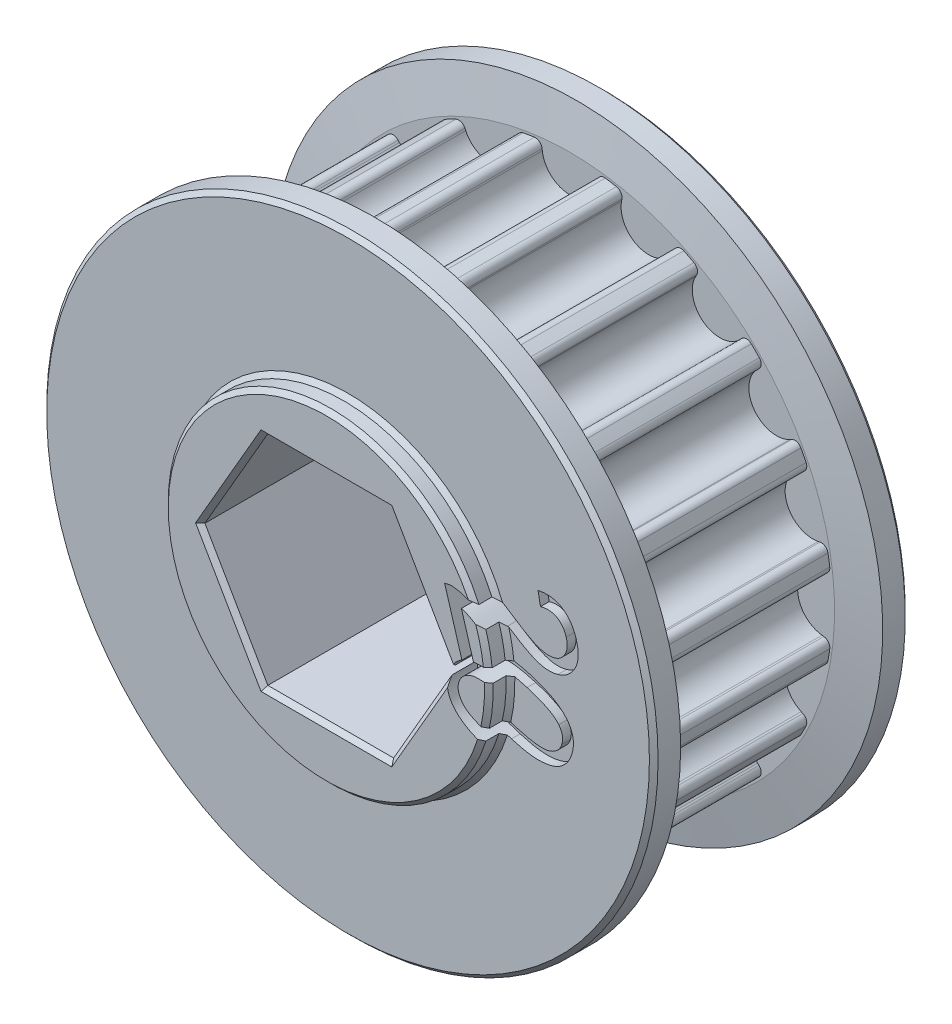
from build123d import *

# Parameters (mm, degrees)
SKETCH2_R                                 = 15.381132683
PULLEY_DEPTH                              = 5.500000049
CUT_TOOTH_DEPTH                           = 5.500000049
BLEND_TOOTH_R                             = 0.4
TOOTH_PATTERN_COUNT                       = 20
BLEND_TOOTH_OF_TOOTH_PATTERN_R            = 0.4
SIDEWALL_START                            = 5.500000049
SKETCH3_R                                 = 17.921132683
SIDEWALL_DEPTH                            = 2.000000064
SIDEWALL_CHAMFER_SIZE                     = 2.400000026
SIDEWALL_CHAMFER_SIZE2                    = 0.423184758
SIDEWALL_CHAMFER_PART_2_SIZE              = 2.400000026
SIDEWALL_CHAMFER_PART_2_SIZE2             = 0.423184758
SKETCH5_R                                 = 9.525
BEARING_SPACER_MANUAL_SUPPRESS_DEPTH      = 8.770000113
BEARING_SPACER_MANUAL_SUPPRESS_DEPTH_BACK = 8.770000113
HEX_SHAFT_DEPTH                           = 63.5
CHAMFERS_SIZE                             = 0.254
CUT_EXTRUDE_START                         = 6.992000113
CUT_EXTRUDE_4419_DEPTH                    = 2.54


with BuildPart() as part:
    # Sketch2 → pulley (new body, symmetric)
    with BuildSketch(Plane.XY):
        Circle(SKETCH2_R)
    extrude(amount=PULLEY_DEPTH, both=True)

    # tooth → cut tooth (cut, symmetric)
    with BuildSketch(Plane.XY):
        with BuildLine():
            Line((-2.132711961, 19.01672513), (-1.612887548, 14.783095032))
            ThreePointArc((-1.612887548, 14.783095032), (0, 13.356132669), (1.612887548, 14.783095032))
            Line((1.612887548, 14.783095032), (2.132711961, 19.01672513))
            Line((2.132711961, 19.01672513), (-2.132711961, 19.01672513))
        make_face()
    cut_tooth = extrude(amount=CUT_TOOTH_DEPTH, both=True, mode=Mode.SUBTRACT)

    # blend tooth
    blend_tooth_edges = [part.edges().sort_by_distance(p)[0] for p in [
        (1.675084427, 15.289647961, 0),
        (-1.675084427, 15.289647961, 0),
    ]]
    fillet(blend_tooth_edges, radius=BLEND_TOOTH_R)

    # tooth pattern: cut tooth ×20 about axis
    tooth_pattern_axis = Axis((0, 0, 0), (0, 0, 1))
    for i in range(1, TOOTH_PATTERN_COUNT):
        add(cut_tooth.rotate(tooth_pattern_axis, i * 360 / TOOTH_PATTERN_COUNT), mode=Mode.SUBTRACT)

    # blend tooth of tooth pattern
    blend_tooth_of_tooth_pattern_edges = [part.edges().sort_by_distance(p)[0] for p in [
        (-3.131661098, 15.058948881, 0),
        (-6.317861018, 14.023689771, 0),
        (-7.631857816, 13.354174961, 0),
        (-10.342201353, 11.384995116, 0),
        (-11.384995116, 10.342201353, 0),
        (-13.354174961, 7.631857816, 0),
        (-14.023689771, 6.317861018, 0),
        (-15.058948881, 3.131661098, 0),
        (-15.289647961, 1.675084427, 0),
        (-15.289647961, -1.675084427, 0),
        (-15.058948881, -3.131661098, 0),
        (-14.023689771, -6.317861018, 0),
        (-13.354174961, -7.631857816, 0),
        (-11.384995116, -10.342201353, 0),
        (-10.342201353, -11.384995116, 0),
        (-7.631857816, -13.354174961, 0),
        (-6.317861018, -14.023689771, 0),
        (-3.131661098, -15.058948881, 0),
        (-1.675084427, -15.289647961, 0),
        (1.675084427, -15.289647961, 0),
        (3.131661098, -15.058948881, 0),
        (6.317861018, -14.023689771, 0),
        (7.631857816, -13.354174961, 0),
        (10.342201353, -11.384995116, 0),
        (11.384995116, -10.342201353, 0),
        (13.354174961, -7.631857816, 0),
        (14.023689771, -6.317861018, 0),
        (15.058948881, -3.131661098, 0),
        (15.289647961, -1.675084427, 0),
        (15.289647961, 1.675084427, 0),
        (15.058948881, 3.131661098, 0),
        (14.023689771, 6.317861018, 0),
        (13.354174961, 7.631857816, 0),
        (11.384995116, 10.342201353, 0),
        (10.342201353, 11.384995116, 0),
        (7.631857816, 13.354174961, 0),
        (6.317861018, 14.023689771, 0),
        (3.131661098, 15.058948881, 0),
    ]]
    fillet(blend_tooth_of_tooth_pattern_edges, radius=BLEND_TOOTH_OF_TOOTH_PATTERN_R)

    # Sketch3 → sidewall (add)
    with BuildSketch(Plane.XY.offset(SIDEWALL_START)):
        Circle(SKETCH3_R)
    sidewall = extrude(amount=SIDEWALL_DEPTH)

    # mirror sidewall: sidewall across plane
    add(sidewall.mirror(Plane.XY))

    # sidewall chamfer
    sidewall_chamfer_edges = [part.edges().sort_by_distance(p)[0] for p in [
        (-17.921132683, 0, 5.500000049),
    ]]
    sidewall_chamfer_side = [part.faces().sort_by_distance(p)[0] for p in [
        (-17.414246505, 0, 5.500000049),
    ]]
    chamfer(sidewall_chamfer_edges, length=SIDEWALL_CHAMFER_SIZE, length2=SIDEWALL_CHAMFER_SIZE2, reference=sidewall_chamfer_side[0])

    # sidewall chamfer part 2
    sidewall_chamfer_part_2_edges = [part.edges().sort_by_distance(p)[0] for p in [
        (-17.921132683, 0, -5.500000049),
    ]]
    sidewall_chamfer_part_2_side = [part.faces().sort_by_distance(p)[0] for p in [
        (-17.414246505, 0, -5.500000049),
    ]]
    chamfer(sidewall_chamfer_part_2_edges, length=SIDEWALL_CHAMFER_PART_2_SIZE, length2=SIDEWALL_CHAMFER_PART_2_SIZE2, reference=sidewall_chamfer_part_2_side[0])

    # Sketch5 → bearing spacer (Manual Suppress) (add, two sides)
    with BuildSketch(Plane.XY) as bearing_spacer_manual_suppress_sk:
        Circle(SKETCH5_R)
    extrude(amount=BEARING_SPACER_MANUAL_SUPPRESS_DEPTH)
    extrude(bearing_spacer_manual_suppress_sk.sketch, amount=-BEARING_SPACER_MANUAL_SUPPRESS_DEPTH_BACK)

    # Sketch4 → hex shaft (cut, symmetric)
    with BuildSketch(Plane.XY):
        Polygon((3.688171255, 6.3881), (-3.688171255, 6.3881), (-7.376342509, 0), (-3.688171255, -6.3881), (3.688171255, -6.3881), (7.376342509, 0), align=None)
    extrude(amount=HEX_SHAFT_DEPTH, both=True, mode=Mode.SUBTRACT)

    # chamfers
    chamfers_edges = [part.edges().sort_by_distance(p)[0] for p in [
        (-17.921132683, 0, 7.500000113),
        (-17.921132683, 0, -7.500000113),
        (-9.525, 0, -7.500000113),
        (-9.525, 0, 7.500000113),
        (-9.525, 0, -8.770000113),
        (-9.525, 0, 8.770000113),
        (0, 6.3881, 8.770000113),
        (-5.532256882, 3.19405, 8.770000113),
        (-5.532256882, -3.19405, 8.770000113),
        (0, -6.3881, 8.770000113),
        (5.532256882, -3.19405, 8.770000113),
        (5.532256882, 3.19405, 8.770000113),
        (5.532256882, 3.19405, -8.770000113),
        (5.532256882, -3.19405, -8.770000113),
        (0, -6.3881, -8.770000113),
        (-5.532256882, -3.19405, -8.770000113),
        (-5.532256882, 3.19405, -8.770000113),
        (0, 6.3881, -8.770000113),
    ]]
    chamfer(chamfers_edges, length=CHAMFERS_SIZE)

    # Sketch6 → 4419 (cut)
    with BuildSketch(Plane.XY.offset(CUT_EXTRUDE_START)):
        with BuildLine():
            Line((8.766198019, 0.589858789), (8.07843191, 0.384887202))
            Line((8.07843191, 0.384887202), (6.931331882, 4.236130461))
            add(Edge.make_bspline(
                [(6.931331882, 4.236130461), (6.973928693, 4.24890387), (7.058624263, 4.274301337), (7.188956622, 4.297427056), (7.320577394, 4.308171263), (7.408360376, 4.303777636), (7.45240423, 4.301573196)],
                knots=[0, 0, 0, 0, 0.000133315, 0.000265071, 0.000396329, 0.000528501, 0.000528501, 0.000528501, 0.000528501], degree=3))
            add(Edge.make_bspline(
                [(7.45240423, 4.301573196), (7.526313154, 4.294486229), (7.677039723, 4.280033383), (7.903958115, 4.228030061), (8.136041701, 4.156614255), (8.331820725, 4.078466956), (8.492790819, 4.003004587), (8.622180148, 3.939004595), (8.75826156, 3.867338495), (8.900297464, 3.787001851), (9.047747953, 3.697658951), (9.203000258, 3.602533506), (9.364552461, 3.499056292), (9.473462339, 3.42553063), (9.529285013, 3.387844434)],
                knots=[0, 0, 0, 0, 0.000222539, 0.000453837, 0.00069677, 0.000950595, 0.001085389, 0.001230067, 0.001383616, 0.001546727, 0.001719524, 0.001900804, 0.002092956, 0.00229501, 0.00229501, 0.00229501, 0.00229501], degree=3))
            add(Edge.make_bspline(
                [(9.529285013, 3.387844434), (9.614599201, 3.330180573), (9.779190501, 3.218933311), (10.021913289, 3.065421957), (10.246942179, 2.92510911), (10.457204794, 2.802876813), (10.650966346, 2.696343509), (10.828965964, 2.60545543), (10.991676244, 2.531230748), (11.140639732, 2.471548378), (11.279552066, 2.426926064), (11.411296301, 2.391574377), (11.538778274, 2.366647366), (11.66174668, 2.35191917), (11.779907198, 2.345980544), (11.892998473, 2.353150256), (12.001997275, 2.366625033), (12.071824867, 2.384864422), (12.106247078, 2.393855712)],
                knots=[0, 0, 0, 0, 0.000308902, 0.000595945, 0.000861515, 0.001104426, 0.001325463, 0.001524812, 0.00170385, 0.001861832, 0.00200592, 0.002141295, 0.002270851, 0.002395214, 0.002512621, 0.002625154, 0.00273482, 0.00284144, 0.00284144, 0.00284144, 0.00284144], degree=3))
            add(Edge.make_bspline(
                [(12.106247078, 2.393855712), (12.140684562, 2.405081651), (12.208770866, 2.427276441), (12.304725448, 2.472435455), (12.395111251, 2.523818193), (12.475818005, 2.586386619), (12.551665896, 2.654794725), (12.619040235, 2.732719127), (12.679957702, 2.818868355), (12.733993812, 2.911537215), (12.778236064, 3.010586839), (12.813330509, 3.113355771), (12.836638251, 3.219819436), (12.849021003, 3.329044779), (12.850221664, 3.441173362), (12.839657799, 3.555922962), (12.820404698, 3.674251321), (12.79886897, 3.752680602), (12.787839344, 3.792848534)],
                knots=[0, 0, 0, 0, 0.000108561, 0.000214637, 0.00031756, 0.0004198, 0.000520303, 0.000623567, 0.000728064, 0.000836499, 0.000944821, 0.001052981, 0.001161732, 0.001271091, 0.001382227, 0.001497485, 0.00161644, 0.001741323, 0.001741323, 0.001741323, 0.001741323], degree=3))
            add(Edge.make_bspline(
                [(12.787839344, 3.792848534), (12.774641239, 3.834707149), (12.748855912, 3.91648693), (12.69767548, 4.031579691), (12.63886556, 4.137355115), (12.574592323, 4.235529839), (12.499113341, 4.322173155), (12.417846455, 4.400663876), (12.327901181, 4.468667308), (12.232005618, 4.528332076), (12.129060371, 4.57624541), (12.02124193, 4.613954076), (11.908366485, 4.637999366), (11.790969182, 4.652234147), (11.668938301, 4.652592231), (11.542456361, 4.643003051), (11.411643971, 4.620117688), (11.324076942, 4.597318695), (11.278952117, 4.585569974)],
                knots=[0, 0, 0, 0, 0.000131588, 0.000257086, 0.000377018, 0.000494483, 0.000608323, 0.000720985, 0.000832859, 0.000945947, 0.001059183, 0.001172815, 0.001287861, 0.001404721, 0.001526969, 0.001653303, 0.001784844, 0.001924701, 0.001924701, 0.001924701, 0.001924701], degree=3))
            Line((11.278952117, 4.585569974), (11.135718959, 5.342483125))
            add(Edge.make_bspline(
                [(11.135718959, 5.342483125), (11.204697722, 5.355186393), (11.339127766, 5.379943302), (11.538736352, 5.396524061), (11.729960118, 5.39867513), (11.912855296, 5.383007101), (12.087326445, 5.349247288), (12.253591184, 5.299632235), (12.412369273, 5.234748757), (12.561350204, 5.150876668), (12.700661422, 5.052211173), (12.830182114, 4.938850446), (12.949164328, 4.81088582), (13.057992973, 4.668044387), (13.157177671, 4.510811286), (13.244344348, 4.337988601), (13.322811474, 4.151716772), (13.364286535, 4.020420081), (13.385467346, 3.953368452)],
                knots=[0, 0, 0, 0, 0.000210303, 0.00040985, 0.000600009, 0.000783458, 0.000959511, 0.001132185, 0.001303248, 0.001472951, 0.001643908, 0.001814543, 0.0019884, 0.002167203, 0.002352537, 0.002545264, 0.002747291, 0.002958144, 0.002958144, 0.002958144, 0.002958144], degree=3))
            add(Edge.make_bspline(
                [(13.385467346, 3.953368452), (13.404265986, 3.884891979), (13.441005143, 3.751064855), (13.476358108, 3.550659046), (13.495889354, 3.35704857), (13.496271151, 3.169608742), (13.477180998, 2.989025672), (13.443208993, 2.814532451), (13.389775385, 2.646712437), (13.317720069, 2.487377523), (13.233381012, 2.336762539), (13.135292329, 2.199251962), (13.026285302, 2.074872672), (12.905455129, 1.964383391), (12.773662348, 1.866077306), (12.63035296, 1.780698287), (12.474428963, 1.709645407), (12.364701808, 1.673761971), (12.308749128, 1.65546409)],
                knots=[0, 0, 0, 0, 0.000212932, 0.000416145, 0.000609657, 0.000796107, 0.000977332, 0.001153623, 0.001328569, 0.00150434, 0.001677406, 0.001845634, 0.002010113, 0.002172662, 0.002335899, 0.002502557, 0.002672192, 0.0028487, 0.0028487, 0.0028487, 0.0028487], degree=3))
            add(Edge.make_bspline(
                [(12.308749128, 1.65546409), (12.250170793, 1.639717555), (12.132957395, 1.608209236), (11.950953691, 1.584958513), (11.765745382, 1.576532367), (11.575068717, 1.59005538), (11.376703949, 1.621993285), (11.169095403, 1.679449415), (10.94957845, 1.756456674), (10.759281475, 1.838587313), (10.595601297, 1.917476032), (10.459121288, 1.991496161), (10.308495548, 2.073216535), (10.145936708, 2.168311674), (9.970664749, 2.273807955), (9.781908866, 2.390343287), (9.581553115, 2.518747191), (9.443630046, 2.608225861), (9.372469401, 2.654391886)],
                knots=[0, 0, 0, 0, 0.000181784, 0.000363744, 0.000549107, 0.000737198, 0.000936133, 0.001150887, 0.001382461, 0.001633606, 0.001772219, 0.001927437, 0.002099301, 0.002286306, 0.002492349, 0.002713024, 0.002951769, 0.003206243, 0.003206243, 0.003206243, 0.003206243], degree=3))
            add(Edge.make_bspline(
                [(9.372469401, 2.654391886), (9.314068403, 2.692737903), (9.202415741, 2.766048891), (9.041956723, 2.869875539), (8.896397841, 2.962064836), (8.766456958, 3.044427115), (8.651375157, 3.114023657), (8.551373165, 3.172922471), (8.467040862, 3.220794372), (8.336908311, 3.290716169), (8.156892649, 3.373554883), (7.993003421, 3.424063994), (7.914207686, 3.448348095)],
                knots=[0, 0, 0, 0, 0.000209594, 0.000400709, 0.000573351, 0.000726487, 0.000862228, 0.000976795, 0.001074662, 0.001153106, 0.001420028, 0.001667194, 0.001667194, 0.001667194, 0.001667194], degree=3))
            Line((7.914207686, 3.448348095), (8.766198019, 0.589858789))
        make_face()
        with BuildLine():
            add(Edge.make_bspline(
                [(10.712644623, 0.822636319), (10.796339195, 0.796735741), (10.959865988, 0.746129847), (11.196675734, 0.664719893), (11.419102692, 0.580882985), (11.627024336, 0.494780236), (11.820037486, 0.404912049), (11.997480493, 0.310768833), (12.161679916, 0.215838197), (12.311688867, 0.1172939), (12.447633809, 0.013371908), (12.574886137, -0.090386031), (12.687819551, -0.201514766), (12.792910623, -0.313489568), (12.885334541, -0.431132794), (12.967252103, -0.552348076), (13.037980982, -0.677423324), (13.097265336, -0.80631255), (13.146419065, -0.938445679), (13.18017353, -1.075312152), (13.204402533, -1.214696196), (13.214266858, -1.358258029), (13.209617702, -1.504824276), (13.195202764, -1.655608416), (13.166738612, -1.80961974), (13.138494789, -1.912152537), (13.124147696, -1.964236407)],
                knots=[0, 0, 0, 0, 0.00026282, 0.000513512, 0.000751101, 0.000975829, 0.0011885, 0.001389551, 0.001578245, 0.001757354, 0.001927506, 0.002091451, 0.002249507, 0.002402424, 0.002551876, 0.002697767, 0.002840969, 0.002982402, 0.003123025, 0.003263181, 0.003404668, 0.00354701, 0.003693994, 0.003844134, 0.004001071, 0.004163094, 0.004163094, 0.004163094, 0.004163094], degree=3))
            add(Edge.make_bspline(
                [(13.124147696, -1.964236407), (13.099586418, -2.039427072), (13.051680508, -2.186083816), (12.951465174, -2.38988681), (12.833111878, -2.573271988), (12.693275181, -2.733489155), (12.537197982, -2.872405912), (12.364384575, -2.990347338), (12.174825738, -3.085201057), (11.968843622, -3.157986657), (11.74772066, -3.210699745), (11.511273804, -3.244411364), (11.259122079, -3.261703282), (11.038453762, -3.260218071), (10.850580591, -3.249611659), (10.698348766, -3.231286977), (10.536026165, -3.208055931), (10.363788283, -3.177138564), (10.1821179, -3.136959103), (9.98955944, -3.091648286), (9.788138026, -3.036922377), (9.650685613, -2.997113691), (9.580361819, -2.976746658)],
                knots=[0, 0, 0, 0, 0.000237053, 0.000462364, 0.000679153, 0.000890096, 0.001098256, 0.001304429, 0.001515924, 0.001732294, 0.001958405, 0.002196767, 0.00244802, 0.002715968, 0.002858229, 0.003012313, 0.00317576, 0.003350147, 0.003537116, 0.003733882, 0.003943546, 0.004163189, 0.004163189, 0.004163189, 0.004163189], degree=3))
            add(Edge.make_bspline(
                [(9.580361819, -2.976746658), (9.497080032, -2.951261666), (9.334761486, -2.9015907), (9.099790372, -2.821553139), (8.879724402, -2.737264806), (8.673362745, -2.650913569), (8.480434056, -2.562700366), (8.302602122, -2.470024812), (8.13908241, -2.374734018), (7.988890158, -2.277460491), (7.851817404, -2.175223883), (7.726589672, -2.069136691), (7.61029343, -1.961026421), (7.508215039, -1.845846018), (7.413602926, -1.729703217), (7.331932206, -1.607893186), (7.26146304, -1.482556108), (7.20039154, -1.354298604), (7.151595566, -1.221794051), (7.11774464, -1.084593049), (7.092993378, -0.944387525), (7.085916206, -0.799940724), (7.087368444, -0.652490234), (7.104472096, -0.501455581), (7.132441234, -0.34657787), (7.160650981, -0.24360519), (7.175032589, -0.1911087)],
                knots=[0, 0, 0, 0, 0.000261272, 0.000509227, 0.000744508, 0.000968097, 0.001180247, 0.001380725, 0.001569419, 0.00174785, 0.001917261, 0.002082, 0.002240094, 0.00239309, 0.002543312, 0.002689203, 0.002832404, 0.002974359, 0.003114982, 0.003255138, 0.003397843, 0.003541337, 0.003688295, 0.003839789, 0.003996727, 0.004159945, 0.004159945, 0.004159945, 0.004159945], degree=3))
            add(Edge.make_bspline(
                [(7.175032589, -0.1911087), (7.197032183, -0.123053132), (7.240005827, 0.009885493), (7.327657381, 0.195746495), (7.429184525, 0.365460871), (7.546425422, 0.518062031), (7.680719813, 0.652804056), (7.828756252, 0.771825086), (7.993627951, 0.87329143), (8.112362769, 0.925662449), (8.172725616, 0.952287022)],
                knots=[0, 0, 0, 0, 0.000214384, 0.000418775, 0.000614866, 0.000806768, 0.00099449, 0.001184243, 0.001375473, 0.001573225, 0.001573225, 0.001573225, 0.001573225], degree=3))
            add(Edge.make_bspline(
                [(8.172725616, 0.952287022), (8.250763912, 0.979843672), (8.412333841, 1.036896762), (8.674689722, 1.084788074), (8.958782178, 1.108014911), (9.265764487, 1.10270648), (9.595372682, 1.072339635), (9.948335131, 1.015865397), (10.324164278, 0.932686232), (10.580051627, 0.860197673), (10.712644623, 0.822636319)],
                knots=[0, 0, 0, 0, 0.000247955, 0.000513364, 0.000797098, 0.001102108, 0.00143312, 0.001789389, 0.002173767, 0.002587135, 0.002587135, 0.002587135, 0.002587135], degree=3))
        make_face()
        with BuildLine():
            add(Edge.make_bspline(
                [(10.494090581, 0.087949003), (10.37906978, 0.121282043), (10.159434727, 0.184932304), (9.840755908, 0.263434041), (9.549098192, 0.321979775), (9.283670901, 0.360896404), (9.045711941, 0.382080947), (8.83371761, 0.382961948), (8.648008791, 0.365475054), (8.487545169, 0.324604945), (8.348436873, 0.270230498), (8.224315574, 0.207328513), (8.113570492, 0.135544081), (8.015473921, 0.054537033), (7.931465039, -0.037117019), (7.860602631, -0.137966536), (7.802321661, -0.247689626), (7.776087342, -0.326484517), (7.762782442, -0.366445841)],
                knots=[0, 0, 0, 0, 0.000359233, 0.000685964, 0.000984303, 0.001251302, 0.001490429, 0.00170034, 0.001886606, 0.002048323, 0.002195307, 0.002333915, 0.002465086, 0.002590456, 0.002714548, 0.002836847, 0.002959456, 0.003085626, 0.003085626, 0.003085626, 0.003085626], degree=3))
            add(Edge.make_bspline(
                [(7.762782442, -0.366445841), (7.752205221, -0.407392146), (7.731371068, -0.488044867), (7.719589654, -0.611909114), (7.72265282, -0.734880328), (7.74457251, -0.857250563), (7.782073125, -0.979037847), (7.835525521, -1.100440313), (7.90589171, -1.221001007), (7.992806806, -1.343011027), (8.106454267, -1.463564341), (8.251606742, -1.58076888), (8.429999506, -1.694907838), (8.640580631, -1.807690012), (8.883596563, -1.919752501), (9.159293466, -2.03051731), (9.468217564, -2.138583206), (9.6863132, -2.205760593), (9.800150629, -2.240824573)],
                knots=[0, 0, 0, 0, 0.000126701, 0.000249565, 0.000371863, 0.000494678, 0.000621228, 0.000753371, 0.000891671, 0.001039374, 0.001201858, 0.001386995, 0.001597623, 0.001836301, 0.002103128, 0.002400061, 0.002727319, 0.003084645, 0.003084645, 0.003084645, 0.003084645], degree=3))
            add(Edge.make_bspline(
                [(9.800150629, -2.240824573), (9.915142356, -2.27428881), (10.135489833, -2.338413076), (10.45502333, -2.415274535), (10.746983738, -2.476816253), (11.012257897, -2.514657438), (11.250589809, -2.536442836), (11.462085494, -2.536631044), (11.64794186, -2.521068717), (11.80792961, -2.479882137), (11.947016972, -2.425545583), (12.071445024, -2.362738353), (12.182437652, -2.289745191), (12.279216139, -2.206094142), (12.364443927, -2.114483615), (12.435266454, -2.012139215), (12.492648526, -1.900249099), (12.520061574, -1.820564088), (12.533928306, -1.780255886)],
                knots=[0, 0, 0, 0, 0.000359233, 0.000688363, 0.000985735, 0.001253955, 0.001491853, 0.001702998, 0.001887908, 0.002049625, 0.00219661, 0.002335217, 0.002467066, 0.002594031, 0.002718124, 0.002841434, 0.002966237, 0.003093993, 0.003093993, 0.003093993, 0.003093993], degree=3))
            add(Edge.make_bspline(
                [(12.533928306, -1.780255886), (12.544948723, -1.739735529), (12.566530226, -1.660383705), (12.578988969, -1.539387796), (12.579790312, -1.421316898), (12.564846245, -1.304948905), (12.53386183, -1.191174163), (12.486675287, -1.080450773), (12.428100171, -0.97036461), (12.377250088, -0.902534158), (12.351182554, -0.867761892)],
                knots=[0, 0, 0, 0, 0.000125783, 0.000246323, 0.000363626, 0.000479412, 0.00059713, 0.000716143, 0.000839915, 0.000970106, 0.000970106, 0.000970106, 0.000970106], degree=3))
            add(Edge.make_bspline(
                [(12.351182554, -0.867761892), (12.311999989, -0.822968355), (12.229064673, -0.728156642), (12.072553809, -0.602304088), (11.886280439, -0.479334537), (11.668911808, -0.358528005), (11.420487572, -0.240660239), (11.140470749, -0.126134092), (10.828734725, -0.015266473), (10.608786168, 0.052573038), (10.494090581, 0.087949003)],
                knots=[0, 0, 0, 0, 0.000178252, 0.000377295, 0.000599896, 0.000847556, 0.001122599, 0.00142436, 0.001754771, 0.002114824, 0.002114824, 0.002114824, 0.002114824], degree=3))
        make_face(mode=Mode.SUBTRACT)
    extrude(amount=CUT_EXTRUDE_4419_DEPTH, mode=Mode.SUBTRACT)


solid = part.part
